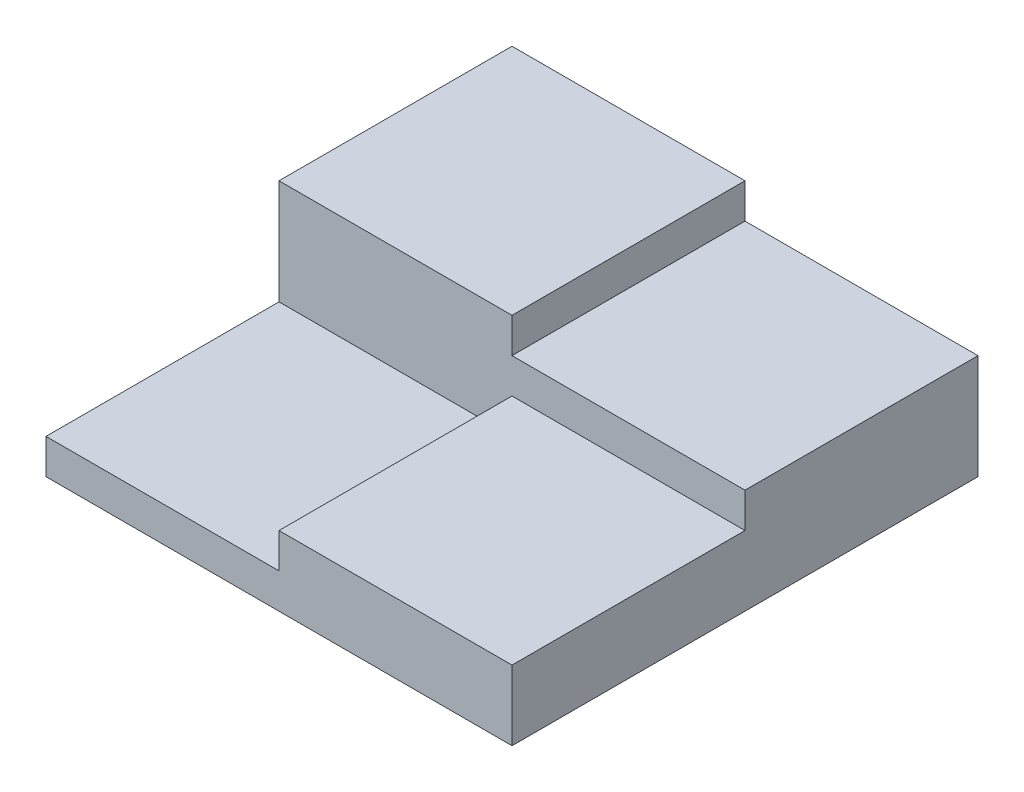
from build123d import *

# Parameters (mm, degrees)
SKETCH1_W      = 20
SKETCH1_H      = 20
EXTRUDE1_DEPTH = 1.5
SKETCH2_W      = 20
SKETCH2_H      = 10
EXTRUDE2_DEPTH = 3
SKETCH3_W      = 10
SKETCH3_H      = 10
EXTRUDE3_DEPTH = 1.5
SKETCH4_W      = 10
SKETCH4_H      = 10
EXTRUDE4_DEPTH = 1.5


with BuildPart() as part:
    # Sketch1 → Extrude1 (new body)
    with BuildSketch(Plane(origin=(0, 0, 0), x_dir=(1, 0, 0), z_dir=(0, 1, 0))):
        Rectangle(SKETCH1_W, SKETCH1_H)
    extrude(amount=EXTRUDE1_DEPTH)

    # Sketch2 → Extrude2 (add)
    with BuildSketch(Plane(origin=(0, 1.5, 0), x_dir=(1, 0, 0), z_dir=(0, 1, 0))):
        with Locations((0, 5)):
            Rectangle(SKETCH2_W, SKETCH2_H)
    extrude(amount=EXTRUDE2_DEPTH)

    # Sketch3 → Extrude3 (add)
    with BuildSketch(Plane(origin=(0, 1.5, 0), x_dir=(1, 0, 0), z_dir=(0, 1, 0))):
        with Locations((5, -5)):
            Rectangle(SKETCH3_W, SKETCH3_H)
    extrude(amount=EXTRUDE3_DEPTH)

    # Sketch4 → Extrude4 (add)
    with BuildSketch(Plane(origin=(0, 4.5, 0), x_dir=(-1, 0, 0), z_dir=(0, 1, 0))):
        with Locations((5, -5)):
            Rectangle(SKETCH4_W, SKETCH4_H)
    extrude(amount=EXTRUDE4_DEPTH)


solid = part.part
